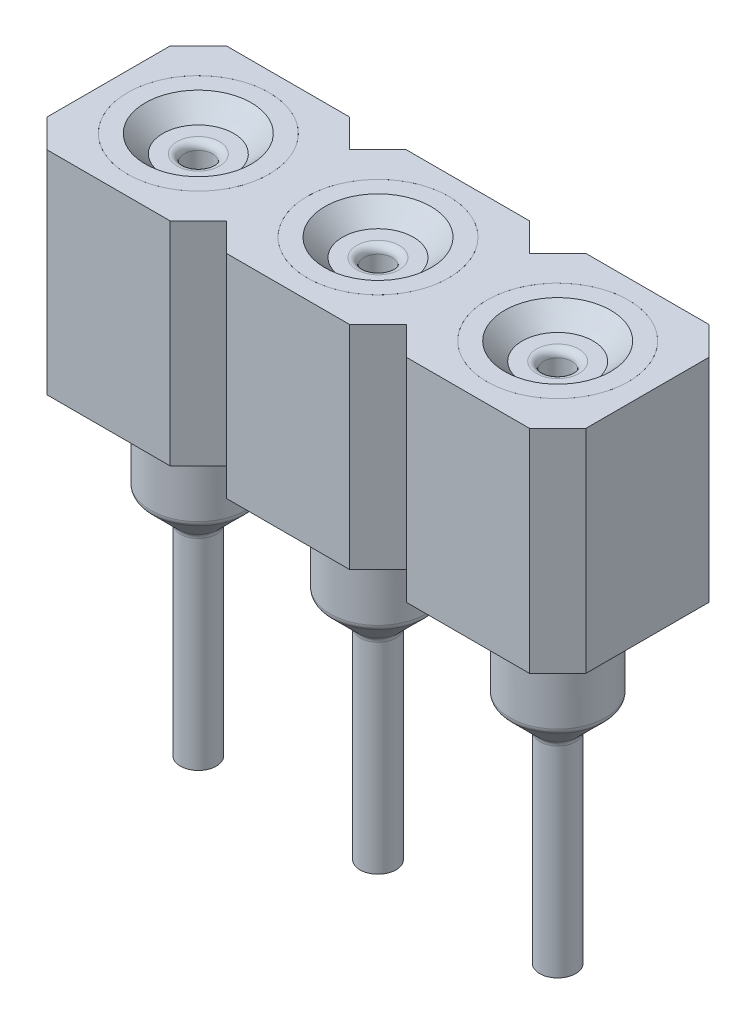
from build123d import *

# Parameters (mm, degrees)
SKETCH1_W           = 7.62
SKETCH1_H           = 2.54
SKETCH1_W_2         = 0.52
SKETCH1_H_2         = 0.52
BOSS_EXTRUDE1_DEPTH = 3
FILLET1_R           = 0.1
LPATTERN1_COUNT     = 2
LPATTERN1_PITCH     = 2.54
LPATTERN1_COL_COUNT = 2
LPATTERN1_COL_PITCH = 2.54
LPATTERN2_COUNT     = 2
LPATTERN2_PITCH     = 2.54
LPATTERN2_2_COUNT   = 2
LPATTERN2_2_PITCH   = 2.54
CUT_EXTRUDE1_DEPTH  = 3


with BuildPart() as part:
    # Sketch1 → Boss-Extrude1 (new body)
    with BuildSketch(Plane(origin=(0, 0, 0), x_dir=(1, 0, 0), z_dir=(0, 1, 0))):
        Rectangle(SKETCH1_W, SKETCH1_H)
        Rectangle(SKETCH1_W_2, SKETCH1_H_2, mode=Mode.SUBTRACT)
        with Locations((2.54, 0)):
            Rectangle(SKETCH1_W_2, SKETCH1_H_2, mode=Mode.SUBTRACT)
        with Locations((-2.54, 0)):
            Rectangle(SKETCH1_W_2, SKETCH1_H_2, mode=Mode.SUBTRACT)
    extrude(amount=BOSS_EXTRUDE1_DEPTH)

    # Sketch3 → Cut-Revolve1 (revolve, cut)
    with BuildSketch(Plane.XY):
        Polygon((0, 3), (0, 0), (0.675, 0), (0.675, 0.46), (1, 0.46), (1, 3), align=None)
    cut_revolve1 = revolve(axis=Axis((0, 3, 0), (0, -1, 0)), mode=Mode.SUBTRACT)

    # LPattern1: Cut-Revolve1 ×2
    with Locations(*[(i * LPATTERN1_PITCH, 0, 0) for i in range(1, LPATTERN1_COUNT)]):
        add(cut_revolve1, mode=Mode.SUBTRACT)

    # LPattern1 col: Cut-Revolve1 ×2
    with Locations(*[(-i * LPATTERN1_COL_PITCH, 0, 0) for i in range(1, LPATTERN1_COL_COUNT)]):
        add(cut_revolve1, mode=Mode.SUBTRACT)

    # Sketch6 → Cut-Extrude1 (cut)
    with BuildSketch(Plane(origin=(0, 3, 0), x_dir=(1, 0, 0), z_dir=(0, 1, 0))):
        Polygon((-3.41, 1.27), (-3.81, 1.27), (-3.81, 0.87), align=None)
        Polygon((-1.67, 1.27), (-0.87, 1.27), (-1.27, 0.87), align=None)
        Polygon((0.87, 1.27), (1.67, 1.27), (1.27, 0.87), align=None)
        Polygon((-1.67, -1.27), (-0.87, -1.27), (-1.27, -0.87), align=None)
        Polygon((0.87, -1.27), (1.67, -1.27), (1.27, -0.87), align=None)
        Polygon((-3.81, -0.87), (-3.81, -1.27), (-3.41, -1.27), align=None)
        Polygon((3.41, 1.27), (3.81, 1.27), (3.81, 0.87), align=None)
        Polygon((3.81, -0.87), (3.81, -1.27), (3.41, -1.27), align=None)
    extrude(amount=-CUT_EXTRUDE1_DEPTH, mode=Mode.SUBTRACT)


with BuildPart() as body_2:
    # Sketch2 → Revolve1 (revolve)
    with BuildSketch(Plane.XY):
        Polygon((0, 3), (0, -4.62), (0.254, -4.62), (0.254, -1.739), (0.675, -1.318), (0.675, 0.46), (1, 0.46), (1, 3), align=None)
    revolve(axis=Axis((0, 3, 0), (0, -1, 0)))

    # Sketch5 → Cut-Revolve2 (revolve, cut)
    with BuildSketch(Plane.XY):
        Polygon((0, 0.46), (0, 3), (0.75, 3), (0.5, 2.75), (0.2, 2.75), (0.2, 0.46), align=None)
    revolve(axis=Axis((0, 0.46, 0), (0, 1, 0)), mode=Mode.SUBTRACT)

    # Fillet1
    fillet1_edges = [body_2.edges().sort_by_distance(p)[0] for p in [
        (-0.2, 2.75, 0),
        (-0.254, -1.739, 0),
        (-0.675, -1.318, 0),
    ]]
    fillet(fillet1_edges, radius=FILLET1_R)


with BuildPart() as lpattern2_1:
    # LPattern2: pattern copy
    add(body_2.part.moved(Location(Vector(1, 0, 0) * (1 * LPATTERN2_PITCH))))


with BuildPart() as lpattern2_2_1:
    # LPattern2 2: pattern copy
    add(body_2.part.moved(Location(Vector(-1, 0, 0) * (1 * LPATTERN2_2_PITCH))))


solid = Compound([part.part, body_2.part, lpattern2_1.part, lpattern2_2_1.part])
